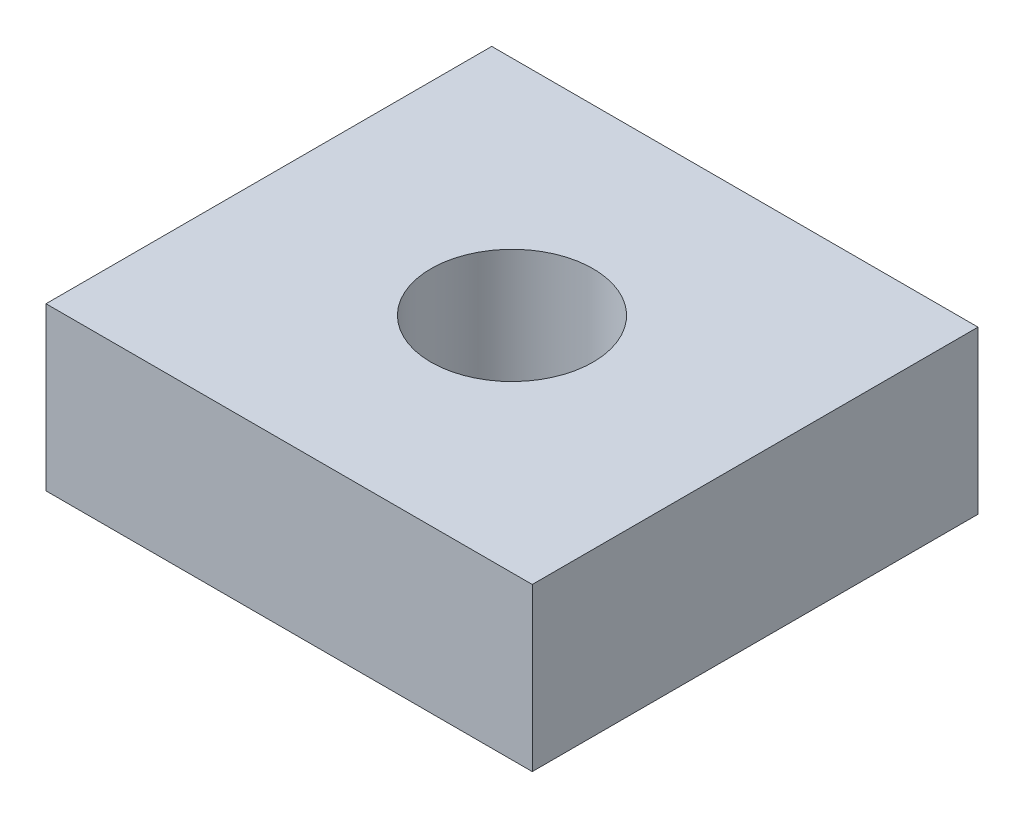
from build123d import *

# Parameters (mm, degrees)
SKETCH1_W           = 76.2
SKETCH1_H           = 69.85
BOSS_EXTRUDE1_DEPTH = 25.4
SKETCH2_R           = 12.7
CUT_EXTRUDE1_DEPTH  = 26.4


with BuildPart() as part:
    # Sketch1 → Boss-Extrude1 (new body)
    with BuildSketch(Plane(origin=(0, 0, 0), x_dir=(1, 0, 0), z_dir=(0, 1, 0))):
        Rectangle(SKETCH1_W, SKETCH1_H)
    extrude(amount=BOSS_EXTRUDE1_DEPTH)

    # Sketch2 → Cut-Extrude1 (cut, through all)
    with BuildSketch(Plane(origin=(0, 25.4, 0), x_dir=(1, 0, 0), z_dir=(0, 1, 0))):
        Circle(SKETCH2_R)
    extrude(amount=-CUT_EXTRUDE1_DEPTH, mode=Mode.SUBTRACT)


solid = part.part
